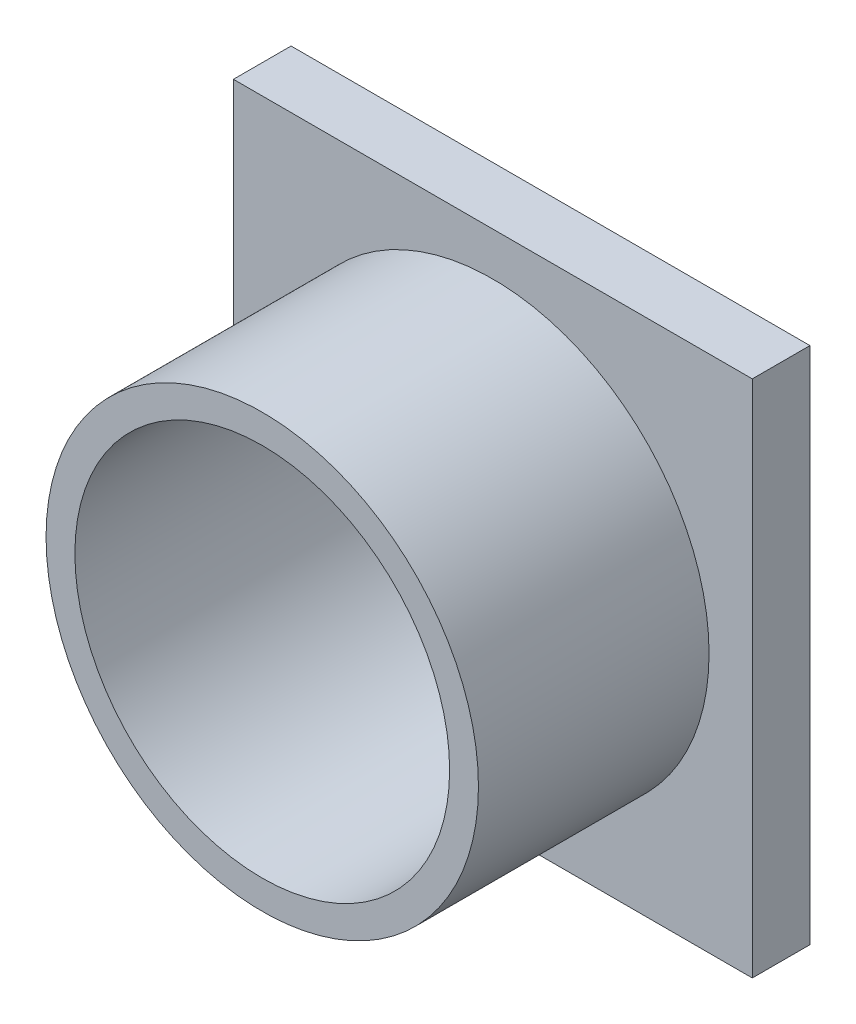
from build123d import *

# Parameters (mm, degrees)
ESQUISSE1_W        = 45
ESQUISSE1_H        = 45
ESQUISSE1_R        = 16.25
BOSS_EXTRU_1_DEPTH = 5
ESQUISSE2_R        = 18.75
ESQUISSE2_R_2      = 16.25
BOSS_EXTRU_2_DEPTH = 20
ESQUISSE3_W        = 4.8
ESQUISSE3_H        = 3.8
BOSS_EXTRU_3_DEPTH = 3


with BuildPart() as part:
    # Esquisse1 → Boss.-Extru.1 (new body)
    with BuildSketch(Plane.XY):
        Rectangle(ESQUISSE1_W, ESQUISSE1_H)
        Circle(ESQUISSE1_R, mode=Mode.SUBTRACT)
    extrude(amount=BOSS_EXTRU_1_DEPTH)

    # Esquisse2 → Boss.-Extru.2 (add)
    with BuildSketch(Plane.XY.offset(5)):
        Circle(ESQUISSE2_R)
        Circle(ESQUISSE2_R_2, mode=Mode.SUBTRACT)
    extrude(amount=BOSS_EXTRU_2_DEPTH)

    # Esquisse3 → Boss.-Extru.3 (add)
    with BuildSketch(Plane(origin=(0, 0, 0), x_dir=(-1, 0, 0), z_dir=(0, 0, -1))):
        with Locations((16.4, 16.9)):
            Rectangle(ESQUISSE3_W, ESQUISSE3_H)
        with Locations((-16.4, 16.9)):
            Rectangle(ESQUISSE3_W, ESQUISSE3_H)
        with Locations((-16.4, -16.9)):
            Rectangle(ESQUISSE3_W, ESQUISSE3_H)
        with Locations((16.4, -16.9)):
            Rectangle(ESQUISSE3_W, ESQUISSE3_H)
    extrude(amount=BOSS_EXTRU_3_DEPTH)


solid = part.part
